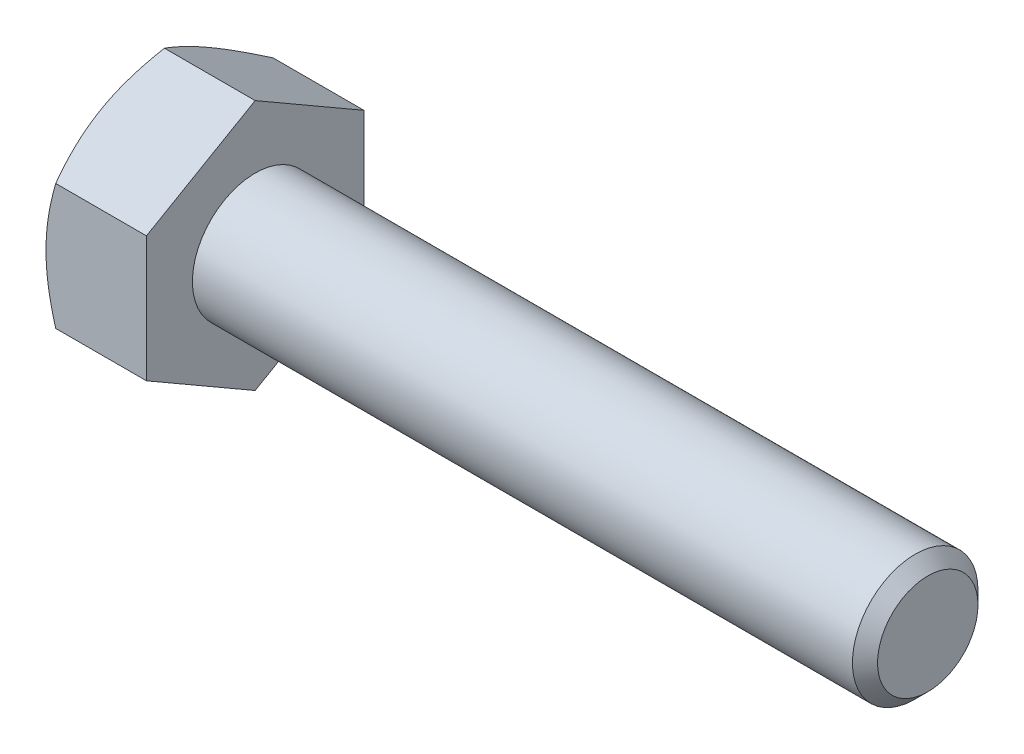
from build123d import *

# Parameters (mm, degrees)
BOSS_EXTRUDE1_DEPTH = 22.4
SKETCH2_R           = 14
BOSS_EXTRUDE2_DEPTH = 150
CHAMFER1_SIZE       = 2.8
SKETCH3_OUTSIDE_W   = 607.642
SKETCH3_OUTSIDE_H   = 615.144
SKETCH3_OUTSIDE_R   = 24.248711306
CUT_EXTRUDE1_DEPTH  = 150
CUT_EXTRUDE1_TAPER  = 60


with BuildPart() as part:
    # Sketch1 → Boss-Extrude1 (new body)
    with BuildSketch(Plane(origin=(0, 0, 0), x_dir=(0, 0, -1), z_dir=(1, 0, 0))):
        Polygon((0, 28), (-24.248711306, 14), (-24.248711306, -14), (0, -28), (24.248711306, -14), (24.248711306, 14), align=None)
    extrude(amount=-BOSS_EXTRUDE1_DEPTH)

    # Sketch2 → Boss-Extrude2 (add)
    with BuildSketch(Plane(origin=(0, 0, 0), x_dir=(0, 0, -1), z_dir=(1, 0, 0))):
        Circle(SKETCH2_R)
    extrude(amount=BOSS_EXTRUDE2_DEPTH)

    # Chamfer1
    chamfer1_edges = [part.edges().sort_by_distance(p)[0] for p in [
        (150, 0, 14),
    ]]
    chamfer(chamfer1_edges, length=CHAMFER1_SIZE)

    # Sketch3 outside → Cut-Extrude1 (cut)
    with BuildSketch(Plane.ZY.offset(22.4)):
        Rectangle(SKETCH3_OUTSIDE_W, SKETCH3_OUTSIDE_H)
        Circle(SKETCH3_OUTSIDE_R, mode=Mode.SUBTRACT)
    extrude(amount=-CUT_EXTRUDE1_DEPTH, taper=CUT_EXTRUDE1_TAPER, mode=Mode.SUBTRACT)


solid = part.part
